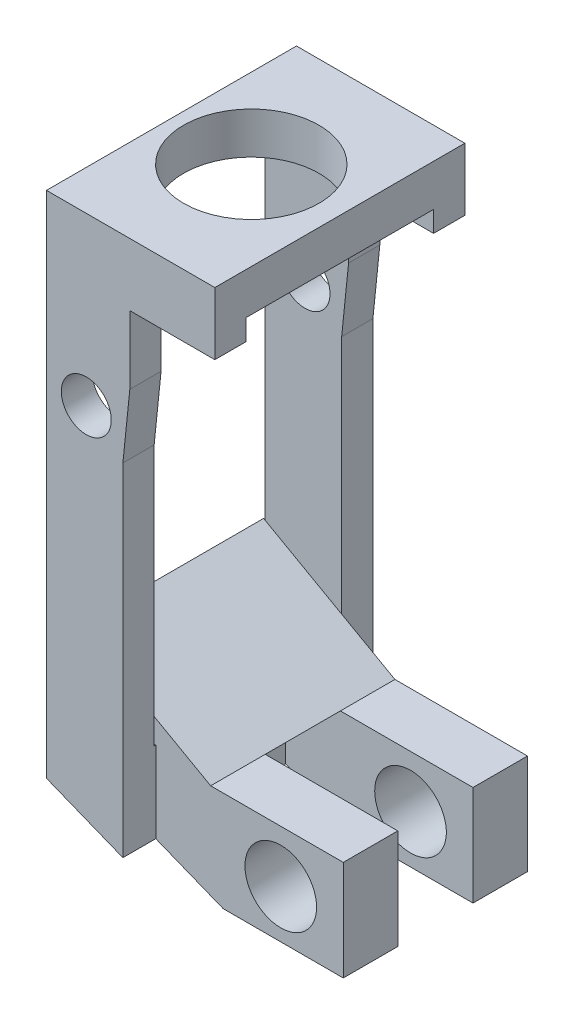
from build123d import *

# Parameters (mm, degrees)
SKETCH_1_R          = 3.25
EXTRUDE_1_DEPTH     = 2
SKETCH_1_3_W        = 8.5
SKETCH_1_3_H        = 1.5
EXTRUDE_2_DEPTH     = 1
SKETCH_2_W          = 4
SKETCH_2_H          = 1.5
EXTRUDE_3_DEPTH     = 6.5
CUT_EXTRUDE_1_DEPTH = 13
SKETCH_4_R          = 1.2
CUT_EXTRUDE_2_DEPTH = 13
SKETCH_5_W          = 0.419062678
SKETCH_5_H          = 3
CUT_EXTRUDE_3_DEPTH = 12
SKETCH_7_W          = 3.667600517
SKETCH_7_H          = 1.5
EXTRUDE_4_DEPTH     = 18
SKETCH_8_W          = 3.667600517
SKETCH_8_H          = 5.48261061
EXTRUDE_5_DEPTH     = 9
SKETCH_9_W          = 2.616581955
SKETCH_9_H          = 4.806747763
EXTRUDE_6_DEPTH     = 9
SKETCH_10_R         = 1.719166773
CUT_EXTRUDE_4_DEPTH = 11.421628998
CUT_EXTRUDE_5_DEPTH = 13
EXTRUDE_7_DEPTH     = 8.843258


with BuildPart() as part:
    # 草图1 → 凸台-拉伸1 (new body)
    with BuildSketch(Plane(origin=(0, 0, 0), x_dir=(1, 0, 0), z_dir=(0, 1, 0))):
        Polygon((-4.25, -4.25), (-4.25, -6), (4.25, -6), (4.25, -4.25), (4.25, 4.25), (4.25, 6), (-4.25, 6), (-4.25, 4.25), align=None)
        Circle(SKETCH_1_R, mode=Mode.SUBTRACT)
    extrude(amount=EXTRUDE_1_DEPTH)

    # 草图1<3> → 凸台-拉伸2 (add)
    with BuildSketch(Plane(origin=(0, 0, 0), x_dir=(1, 0, 0), z_dir=(0, 1, 0))):
        with Locations((0, -5.25)):
            Rectangle(SKETCH_1_3_W, SKETCH_1_3_H)
        with Locations((0, 5.25)):
            Rectangle(SKETCH_1_3_W, SKETCH_1_3_H)
    extrude(amount=-EXTRUDE_2_DEPTH)

    # 草图2 → 凸台-拉伸3 (add)
    with BuildSketch(Plane.XZ.offset(1)):
        with Locations((-1.830937322, -5.25)):
            Rectangle(SKETCH_2_W, SKETCH_2_H)
        with Locations((-1.830937322, 5.25)):
            Rectangle(SKETCH_2_W, SKETCH_2_H)
    extrude(amount=EXTRUDE_3_DEPTH)

    # 草图3 → 切除-拉伸1 (cut, through all)
    with BuildSketch(Plane(origin=(0, 0, -6), x_dir=(-1, 0, 0), z_dir=(0, 0, -1))):
        Polygon((-0.169062678, -4.270246896), (0.163336805, -7.5), (-0.169062678, -7.5), align=None)
    extrude(amount=-CUT_EXTRUDE_1_DEPTH, mode=Mode.SUBTRACT)

    # 草图4 → 切除-拉伸2 (cut, through all)
    with BuildSketch(Plane(origin=(0, 0, -6), x_dir=(-1, 0, 0), z_dir=(0, 0, -1))):
        with Locations((1.920905564, -6)):
            Circle(SKETCH_4_R)
    extrude(amount=-CUT_EXTRUDE_2_DEPTH, mode=Mode.SUBTRACT)

    # 草图5 → 切除-拉伸3 (cut)
    with BuildSketch(Plane(origin=(0, 0, -6), x_dir=(-1, 0, 0), z_dir=(0, 0, -1))):
        with Locations((4.040468661, 0.5)):
            Rectangle(SKETCH_5_W, SKETCH_5_H)
    extrude(amount=-CUT_EXTRUDE_3_DEPTH, mode=Mode.SUBTRACT)

    # 草图7 → 凸台-拉伸4 (add)
    with BuildSketch(Plane.XZ.offset(7.5)):
        with Locations((-1.997137064, 5.25)):
            Rectangle(SKETCH_7_W, SKETCH_7_H)
        with Locations((-1.997137064, -5.25)):
            Rectangle(SKETCH_7_W, SKETCH_7_H)
    extrude(amount=EXTRUDE_4_DEPTH)

    # 草图8 → 凸台-拉伸5 (add)
    with BuildSketch(Plane(origin=(0, 0, 4.5), x_dir=(-1, 0, 0), z_dir=(0, 0, -1))):
        with Locations((1.997137064, -22.758694695)):
            Rectangle(SKETCH_8_W, SKETCH_8_H)
    extrude(amount=EXTRUDE_5_DEPTH)

    # 草图9 → 凸台-拉伸6 (add)
    with BuildSketch(Plane(origin=(-0.163336805, 0, 0), x_dir=(0, 0, -1), z_dir=(1, 0, 0))):
        with Locations((3.113338021, -22.793424654)):
            Rectangle(SKETCH_9_W, SKETCH_9_H)
        with Locations((-3.113338021, -22.793424654)):
            Rectangle(SKETCH_9_W, SKETCH_9_H)
    extrude(amount=EXTRUDE_6_DEPTH)

    # 草图10 → 切除-拉伸4 (cut, through all)
    with BuildSketch(Plane(origin=(0, 0, -4.421628998), x_dir=(-1, 0, 0), z_dir=(0, 0, -1))):
        with Locations((-5.836663195, -22.894386417)):
            Circle(SKETCH_10_R)
    extrude(amount=-CUT_EXTRUDE_4_DEPTH, mode=Mode.SUBTRACT)

    # 草图11 → 切除-拉伸5 (cut, through all)
    with BuildSketch(Plane(origin=(0, 0, -6), x_dir=(-1, 0, 0), z_dir=(0, 0, -1))):
        Polygon((3.830937322, -22.440555736), (-3.067140817, -25.196798535), (0.381898253, -26.676483331), (3.830937322, -26.676483331), align=None)
    extrude(amount=-CUT_EXTRUDE_5_DEPTH, mode=Mode.SUBTRACT)

    # 草图13 → 凸台-拉伸7 (add)
    with BuildSketch(Plane(origin=(0, 0, -4.421628998), x_dir=(-1, 0, 0), z_dir=(0, 0, -1))):
        Polygon((-2.471529716, -20.390050772), (3.830937322, -16.84684298), (3.830937322, -20.390050772), align=None)
    extrude(amount=-EXTRUDE_7_DEPTH)


solid = part.part
